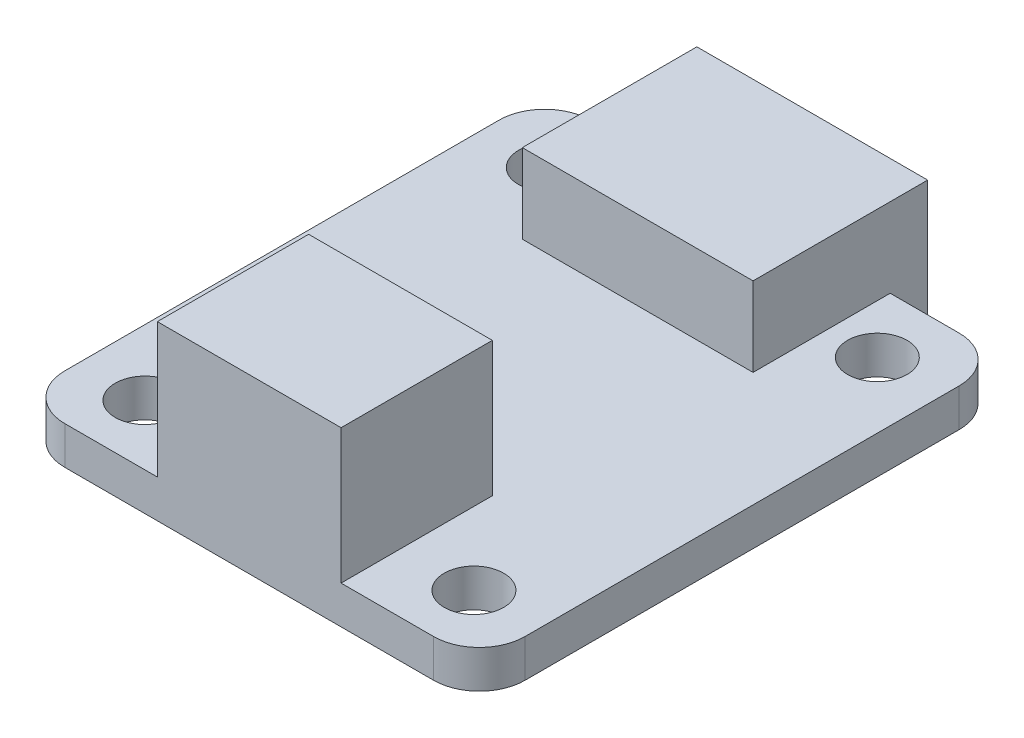
from build123d import *

# Parameters (mm, degrees)
SKETCH1_W           = 20.14
SKETCH1_H           = 23
BOSS_EXTRUDE1_DEPTH = 1.66
SKETCH2_W           = 8.04
SKETCH2_H           = 6.62
BOSS_EXTRUDE2_DEPTH = 7.55
SKETCH3_W           = 10.1
SKETCH3_H           = 7.64
BOSS_EXTRUDE3_DEPTH = 5.13
FILLET1_R           = 2
HOLE1_D             = 2.6


with BuildPart() as part:
    # Sketch1 → Boss-Extrude1 (new body)
    with BuildSketch(Plane(origin=(0, 0, 0), x_dir=(1, 0, 0), z_dir=(0, 1, 0))):
        with Locations((0, 0.178988327)):
            Rectangle(SKETCH1_W, SKETCH1_H)
    extrude(amount=BOSS_EXTRUDE1_DEPTH)

    # Sketch2 → Boss-Extrude2 (add)
    with BuildSketch(Plane.XZ):
        with Locations((0, 8.011011673)):
            Rectangle(SKETCH2_W, SKETCH2_H)
    extrude(amount=-BOSS_EXTRUDE2_DEPTH)

    # Sketch3 → Boss-Extrude3 (add)
    with BuildSketch(Plane.XZ):
        with Locations((0, -9.498988327)):
            Rectangle(SKETCH3_W, SKETCH3_H)
    extrude(amount=-BOSS_EXTRUDE3_DEPTH)

    # Fillet1
    fillet1_edges = [part.edges().sort_by_distance(p)[0] for p in [
        (-10.07, 0.83, -11.678988327),
        (10.07, 0.83, -11.678988327),
        (10.07, 0.83, 11.321011673),
        (-10.07, 0.83, 11.321011673),
    ]]
    fillet(fillet1_edges, radius=FILLET1_R)

    # Hole1 (through all)
    with Locations(Plane(origin=(0, 1.66, 0), x_dir=(1, 0, 0), z_dir=(0, 1, 0))):
        with Locations((-7.2, 8.965942289), (7.2, 8.965942289), (7.2, -8.68646887), (-7.2, -8.68646887)):
            Hole(HOLE1_D / 2)


solid = part.part
